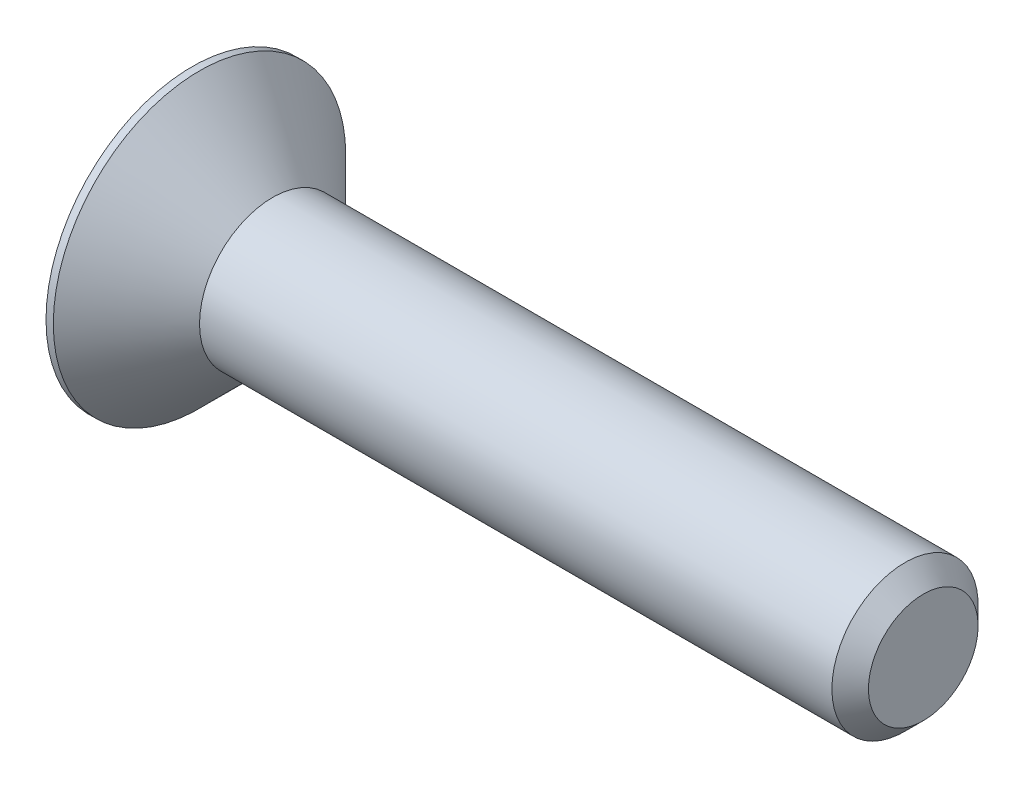
from build123d import *

# Parameters (mm, degrees)
CUT_EXTRUDE1_DEPTH = 0.8


with BuildPart() as part:
    # Sketch2 → Revolve1 (revolve)
    with BuildSketch(Plane.XY):
        Polygon((0, 0), (0, 2), (0.1, 2), (1.1, 1), (9.75, 1), (10, 0.75), (10, 0), align=None)
    revolve(axis=Axis((-2.281841559, 0, 0), (1, 0, 0)))

    # Sketch3 → Cut-Extrude1 (cut)
    with BuildSketch(Plane.ZY):
        Polygon((0.433012702, -0.75), (0.866025404, 0), (0.433012702, 0.75), (-0.433012702, 0.75), (-0.866025404, 0), (-0.433012702, -0.75), align=None)
    extrude(amount=-CUT_EXTRUDE1_DEPTH, mode=Mode.SUBTRACT)


solid = part.part
